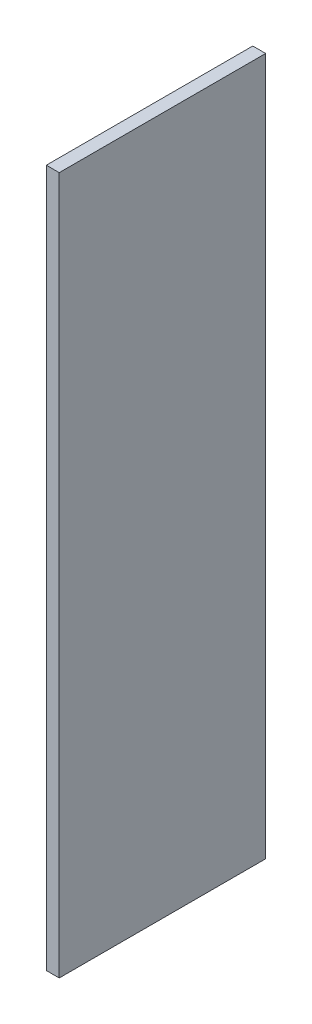
from build123d import *

# Parameters (mm, degrees)
SKETCH1_W           = 288
SKETCH1_H           = 973
BOSS_EXTRUDE1_DEPTH = 18


with BuildPart() as part:
    # Sketch1 → Boss-Extrude1 (new body)
    with BuildSketch(Plane(origin=(0, 0, 0), x_dir=(0, 0, -1), z_dir=(1, 0, 0))):
        with Locations((-123.607933189, -428.719556499)):
            Rectangle(SKETCH1_W, SKETCH1_H)
    extrude(amount=BOSS_EXTRUDE1_DEPTH)


solid = part.part
